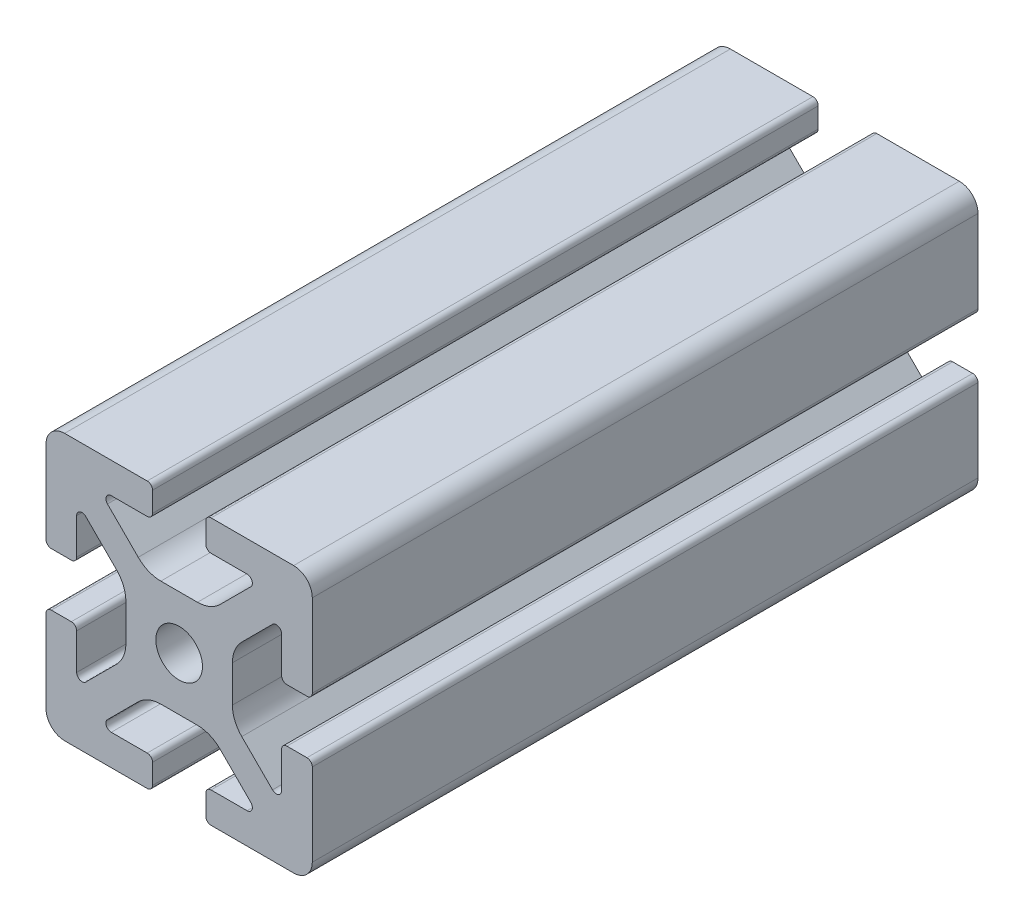
from build123d import *

# Parameters (mm, degrees)
BOSS_EXTRUDE1_DEPTH = 50


with BuildPart() as part:
    # Sketch4 → Boss-Extrude1 (new body, symmetric)
    with BuildSketch(Plane.XY):
        with BuildLine():
            Line((4.8, -20), (17.2, -20))
            ThreePointArc((17.2, -20), (19.179898987, -19.179898987), (20, -17.2))
            Line((20, -17.2), (20, -4.8))
            ThreePointArc((20, -4.8), (19.765685425, -4.234314575), (19.2, -4))
            Line((19.2, -4), (16.190663761, -4))
            ThreePointArc((16.190663761, -4), (15.624978336, -4.234314575), (15.390663761, -4.8))
            Line((15.390663761, -4.8), (15.390663761, -10.2))
            ThreePointArc((15.390663761, -10.2), (14.896810507, -10.939103626), (14.024978336, -10.765685425))
            Line((14.024978336, -10.765685425), (9.40588745, -6.146594539))
            ThreePointArc((9.40588745, -6.146594539), (8.365378244, -4.589362465), (8, -2.752481989))
            Line((8, -2.752481989), (8, 0))
            Line((8, 0), (3.5, 0))
            ThreePointArc((3.5, 0), (2.474873734, -2.474873734), (0, -3.5))
            Line((0, -3.5), (0, -8))
            Line((0, -8), (2.752481989, -8))
            ThreePointArc((2.752481989, -8), (4.589362465, -8.365378244), (6.146594539, -9.40588745))
            Line((6.146594539, -9.40588745), (10.765685425, -14.024978336))
            ThreePointArc((10.765685425, -14.024978336), (10.939103626, -14.896810507), (10.2, -15.390663761))
            Line((10.2, -15.390663761), (4.8, -15.390663761))
            ThreePointArc((4.8, -15.390663761), (4.234314575, -15.624978336), (4, -16.190663761))
            Line((4, -16.190663761), (4, -19.2))
            ThreePointArc((4, -19.2), (4.234314575, -19.765685425), (4.8, -20))
        make_face()
    extrude(amount=BOSS_EXTRUDE1_DEPTH, both=True)

    # Mirror1: part across plane


with BuildPart() as part_1:
    add(part.part)
    add(part.part.mirror(Plane(origin=(0, 0, 0), x_dir=(0, 0, 1), z_dir=(1, 0, 0))))

    # Mirror2: part across plane


with BuildPart() as part_2:
    add(part_1.part)
    add(part_1.part.mirror(Plane.ZX))


solid = part_2.part
